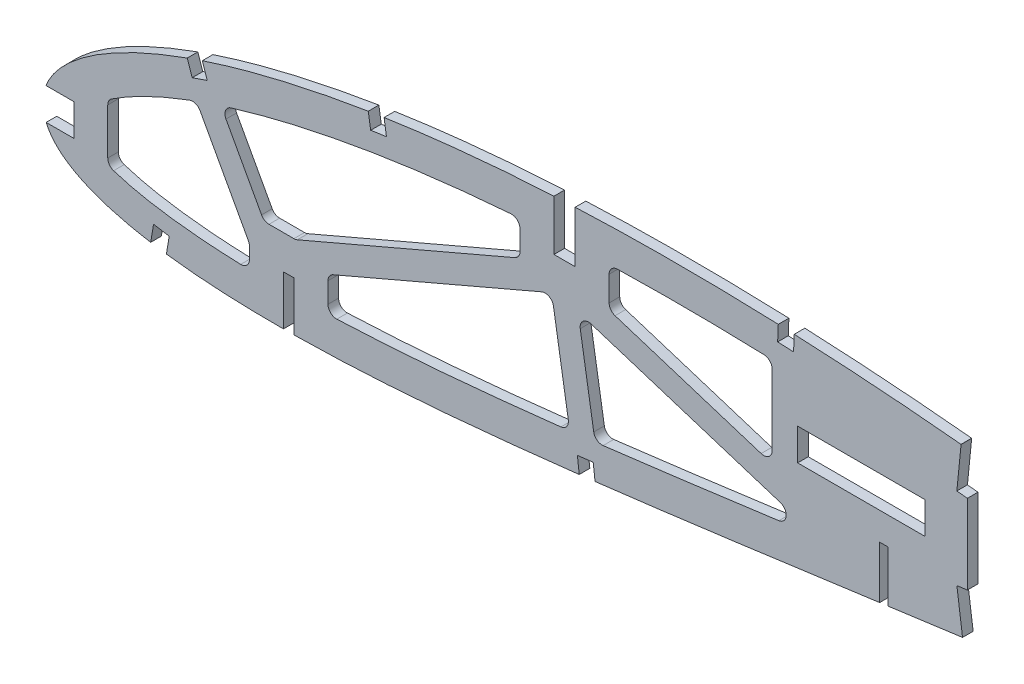
from build123d import *

# Parameters (mm, degrees)
BOSS_EXTRUDE1_DEPTH = 3.175
CUT_EXTRUDE1_DEPTH  = 7.62
SKETCH3_R           = 6.35
CUT_EXTRUDE2_DEPTH  = 7.62
SKETCH4_W           = 38.1
SKETCH4_H           = 9.525
SKETCH4_R           = 6.35
CUT_EXTRUDE3_DEPTH  = 4.1750001
CUT_EXTRUDE4_DEPTH  = 4.1750001
FILLET1_R           = 2.54


with BuildPart() as part:
    # Sketch1 → Boss-Extrude1 (new body)
    with BuildSketch(Plane.XY):
        with BuildLine():
            Line((435.33010469, 0.678691456), (439.172882547, -1.614212492))
            Line((439.172882547, -1.614212492), (434.787151486, -0.678691456))
            add(Edge.make_bspline(
                [(0, 0), (0.11179123, -0.527729161), (0.335887463, -1.58561283), (0.94472768, -3.108527015), (1.749889805, -4.572488672), (2.768272335, -5.973609192), (3.993104005, -7.311505618), (5.421679636, -8.587569541), (7.052598221, -9.801114861), (8.883725224, -10.951589231), (10.912400596, -12.040213999), (13.136344152, -13.066312264), (15.553528081, -14.029563428), (18.161318821, -14.928679795), (20.956528242, -15.765030781), (23.936498821, -16.536578215), (27.097842034, -17.244400464), (30.437517266, -17.886690773), (33.951885298, -18.464101669), (37.637295209, -18.976309975), (41.489964184, -19.423636044), (45.506112459, -19.80514129), (49.681767661, -20.121646285), (54.012767863, -20.373360955), (58.494909036, -20.561083494), (63.123897762, -20.684100336), (67.895200479, -20.744329207), (72.804505265, -20.742674403), (77.847009648, -20.678693244), (83.018406129, -20.555920262), (88.313732191, -20.373577887), (93.728207214, -20.133872554), (99.256947275, -19.839216685), (104.89499369, -19.49060908), (110.637384794, -19.089594814), (116.479134607, -18.639389777), (122.414936441, -18.141116951), (128.439613477, -17.597680601), (134.547832047, -17.011801372), (140.734314746, -16.385333349), (146.993600903, -15.721223571), (153.320115485, -15.021624036), (159.708476563, -14.290267097), (166.152848405, -13.528475979), (172.647781594, -12.740600204), (179.187166024, -11.928145018), (185.765533466, -11.094239816), (192.376967293, -10.242811017), (199.015278084, -9.37376151), (205.674882543, -8.493282903), (212.349358377, -7.600650086), (219.032895906, -6.7004538), (225.719308248, -5.795492203), (232.402082768, -4.886043807), (239.075345122, -3.975877517), (245.732904616, -3.06749205), (252.368240069, -2.160970285), (258.975348295, -1.26081803), (265.547576185, -0.366925322), (272.078863439, 0.518895586), (278.562951189, 1.394000598), (284.993721977, 2.257285217), (291.364542133, 3.108203268), (297.66900214, 3.947074317), (303.806375969, 4.748436439), (309.760626579, 5.554962658), (315.551818652, 6.216135275), (321.27090305, 6.780469964), (326.923820465, 7.243146515), (332.503782957, 7.610821489), (338.004397185, 7.886122043), (343.419107553, 8.072891719), (348.74107448, 8.176671364), (353.963650696, 8.200094537), (359.079707468, 8.150631139), (364.082590991, 8.032268225), (368.965318868, 7.850318702), (373.721079318, 7.610921079), (378.343117125, 7.320601554), (382.824493294, 6.983642622), (387.158963185, 6.607910686), (391.339839301, 6.198906082), (395.360701925, 5.761301701), (399.215684034, 5.304267166), (402.898615263, 4.830811549), (406.403955911, 4.348715399), (409.726063296, 3.862864382), (412.859676284, 3.379461168), (415.799871302, 2.903117573), (418.541899149, 2.440155772), (421.081464376, 1.994901374), (423.414160264, 1.571702591), (425.536750687, 1.175899009), (427.445043551, 0.809456817), (429.136486586, 0.478415007), (430.607934716, 0.184234372), (431.857230885, -0.068940506), (432.88219343, -0.280110359), (433.681265576, -0.445808771), (434.252869013, -0.566300363), (434.596385478, -0.637999126), (434.749014267, -0.670556399), (434.787151486, -0.678691456)],
                knots=[0, 0, 0, 0, 0.003638255, 0.007293231, 0.011028136, 0.014901081, 0.018963272, 0.023258475, 0.027820626, 0.032679082, 0.03785316, 0.043361875, 0.049214679, 0.055422346, 0.061988786, 0.068918036, 0.076211157, 0.083868392, 0.091887411, 0.100265912, 0.108999867, 0.118084529, 0.127514843, 0.13728527, 0.147387917, 0.157816481, 0.168563473, 0.179619128, 0.190977373, 0.202626974, 0.214560478, 0.226767249, 0.239236417, 0.251959004, 0.264923894, 0.278119703, 0.291536035, 0.30516028, 0.318980685, 0.332985499, 0.34716279, 0.361498603, 0.375980747, 0.390597192, 0.405332593, 0.420174823, 0.435109533, 0.450124276, 0.465203068, 0.480333154, 0.495500583, 0.510689775, 0.525887334, 0.541078314, 0.556247233, 0.571381785, 0.58646604, 0.601484515, 0.616424329, 0.631269423, 0.646006524, 0.660620684, 0.675098187, 0.689422858, 0.703581825, 0.716907563, 0.730009274, 0.742952128, 0.755725557, 0.768319951, 0.780724337, 0.792926528, 0.804916041, 0.816679084, 0.828203525, 0.8394749, 0.850481359, 0.861207697, 0.871639326, 0.881763414, 0.891563605, 0.901027365, 0.910138977, 0.918883977, 0.927249278, 0.935221104, 0.942784739, 0.949928188, 0.956638465, 0.962904203, 0.968712288, 0.974054485, 0.978918432, 0.983297219, 0.987180246, 0.990560674, 0.993433357, 0.995790626, 0.997629588, 0.998945816, 0.999736592, 1, 1, 1, 1], degree=3))
            add(Edge.make_bspline(
                [(435.33010469, 0.678691456), (435.296755582, 0.699293055), (435.163488681, 0.781619431), (434.863214309, 0.965803828), (434.363194901, 1.272571896), (433.663211466, 1.69979322), (432.763807452, 2.246333125), (431.664530435, 2.908364558), (430.366066728, 3.683736897), (428.86873043, 4.568782589), (427.172675107, 5.559358025), (425.278546429, 6.651449737), (423.186509465, 7.838875427), (420.897374442, 9.116782681), (418.411926851, 10.4790944), (415.730636684, 11.919657082), (412.854464224, 13.43114364), (409.784513475, 15.00705265), (406.521344218, 16.638681918), (403.066494801, 18.319240705), (399.421116368, 20.040349747), (395.586453278, 21.79282696), (391.56470833, 23.569527811), (387.356993489, 25.359407096), (382.965706604, 27.15470981), (378.392717175, 28.945218407), (373.640732922, 30.722778715), (368.711587102, 32.475875028), (363.608964359, 34.196846251), (358.335340013, 35.87451254), (352.894485425, 37.499762392), (347.289561815, 39.062058655), (341.52524157, 40.553388886), (335.605180365, 41.962892679), (329.534395845, 43.28113527), (323.317713598, 44.500180123), (316.960347344, 45.607856696), (310.479914041, 46.603301327), (303.980682286, 47.431342852), (297.494822244, 48.243461645), (291.0186212, 49.006373108), (284.46326746, 49.736966294), (277.835067652, 50.431127833), (271.140596349, 51.086687253), (264.386630807, 51.700815013), (257.580189535, 52.27171033), (250.727858804, 52.796138155), (243.836864005, 53.273290553), (236.914017847, 53.698972807), (229.966694004, 54.072865307), (223.001944897, 54.392360355), (216.027018499, 54.655256617), (209.049321182, 54.859966995), (202.076096041, 55.004530305), (195.114893299, 55.088037667), (188.172953688, 55.108207309), (181.257823923, 55.064678381), (174.376745271, 54.95595632), (167.537272154, 54.780552763), (160.7466557, 54.538140281), (154.012238926, 54.228824112), (147.341395315, 53.850013849), (140.741361553, 53.404123644), (134.219487317, 52.889280335), (127.782938298, 52.305347044), (121.438460058, 51.65475786), (115.193116172, 50.935743156), (109.053599754, 50.150348891), (103.026626206, 49.300114834), (97.118957953, 48.384577869), (91.33692342, 47.406382542), (85.686763085, 46.366529581), (80.174454785, 45.268067638), (74.805999973, 44.111283189), (69.587081438, 42.899646299), (64.52312301, 41.635267927), (59.619568317, 40.320462769), (54.881388132, 38.958385816), (50.313373811, 37.552127128), (45.920850559, 36.103231966), (41.707138151, 34.617193881), (37.677412709, 33.095067788), (33.834761135, 31.541542875), (30.183686712, 29.958740393), (26.726916941, 28.351485511), (23.468364091, 26.721608068), (20.41035055, 25.073674406), (17.555946308, 23.410211446), (14.907899047, 21.73430892), (12.467321746, 20.050217809), (10.237579271, 18.35899521), (8.219437586, 16.664914738), (6.414173801, 14.97055608), (4.824368385, 13.277086383), (3.449964137, 11.587487839), (2.292762263, 9.903098559), (1.352963468, 8.225512409), (0.632693499, 6.555947979), (0.13123808, 4.895344207), (-0.143255259, 3.246152095), (-0.211578297, 1.607049514), (-0.07042072, 0.534882766), (0, 0)],
                knots=[0, 0, 0, 0, 0.00025409, 0.001015373, 0.002283359, 0.004056577, 0.006330982, 0.009105274, 0.012374489, 0.016134023, 0.02037966, 0.025105976, 0.030306237, 0.035972206, 0.042099522, 0.048678064, 0.055701664, 0.063160184, 0.071045824, 0.079349826, 0.08806291, 0.097175756, 0.106678112, 0.116561573, 0.126814275, 0.137428301, 0.148393618, 0.15969976, 0.171338126, 0.183297699, 0.195569604, 0.208143556, 0.221011593, 0.234161831, 0.24758745, 0.261276822, 0.27522271, 0.289414144, 0.303771199, 0.317689227, 0.331784111, 0.346039677, 0.36044387, 0.37498272, 0.389640454, 0.404403316, 0.419256601, 0.434186749, 0.449177265, 0.464214782, 0.479284009, 0.49436974, 0.509457833, 0.524532346, 0.53957932, 0.554582984, 0.569529546, 0.584403417, 0.599190992, 0.613876838, 0.628447475, 0.642888675, 0.657186054, 0.671325546, 0.685294014, 0.699078147, 0.712665095, 0.726042645, 0.739197713, 0.752117586, 0.764792042, 0.777208152, 0.789355685, 0.80122396, 0.812803686, 0.824082909, 0.835054602, 0.845709571, 0.856037853, 0.866033834, 0.875688843, 0.884997719, 0.893953426, 0.902552897, 0.910789386, 0.918660734, 0.926166253, 0.933302626, 0.94007122, 0.94647478, 0.952517526, 0.958204819, 0.963546652, 0.9685566, 0.973249913, 0.977651041, 0.981787043, 0.985694226, 0.989415109, 0.993001157, 0.996508416, 1, 1, 1, 1], degree=3))
        make_face()
    extrude(amount=BOSS_EXTRUDE1_DEPTH)

    # Sketch2 → Cut-Extrude1 (cut)
    with BuildSketch(Plane(origin=(0, 0, 0), x_dir=(-1, 0, 0), z_dir=(0, 0, -1))):
        Polygon((-252.794440989, 13.221493744), (-250.254440989, 13.221493744), (-250.254440989, -2.115243028), (-250.254440989, -3.986349358), (-252.794440989, -3.050796193), (-252.794440989, -2.115243028), align=None)
        Polygon((-159.131940989, 54.422217902), (-159.131940989, 39.039100326), (-152.781940989, 39.039100326), (-152.781940989, 54.422217902), (-152.781940989, 57.645440557), (-159.131940989, 55.540936844), align=None)
        Polygon((-74.994440989, -5.928775484), (-74.994440989, -20.141805429), (-74.994440989, -20.97642061), (-71.819440989, -22.145862066), (-71.819440989, -20.141805429), (-71.819440989, -5.928775484), align=None)
    extrude(amount=-CUT_EXTRUDE1_DEPTH, mode=Mode.SUBTRACT)

    # Sketch3 → Cut-Extrude2 (cut)
    with BuildSketch(Plane(origin=(0, 0, 0), x_dir=(-1, 0, 0), z_dir=(0, 0, -1))):
        with Locations((-292.383806588, 26.255421435)):
            Circle(SKETCH3_R)
    extrude(amount=-CUT_EXTRUDE2_DEPTH, mode=Mode.SUBTRACT)

    # Sketch4 → Cut-Extrude3 (cut, through all)
    with BuildSketch(Plane.XY.offset(3.175)):
        with BuildLine():
            Line((9.08354865, 6.810338827), (0.76430461, 6.810338827))
            add(Edge.make_bspline(
                [(0.76430461, 6.810338827), (0.726676763, 6.71299191), (0.488212559, 6.077489506), (0.13123808, 4.895344207), (-0.143255259, 3.246152095), (-0.211578297, 1.607049514), (-0.07042072, 0.534882766), (0, 0)],
                knots=[0.98501809, 0.98501809, 0.98501809, 0.98501809, 0.985694226, 0.989415109, 0.993001157, 0.996508416, 1, 1, 1, 1], degree=3))
            add(Edge.make_bspline(
                [(0, 0), (0.11179123, -0.527729161), (0.307969583, -1.453821818), (0.640979835, -2.341032636), (0.803006074, -2.714661173)],
                knots=[0, 0, 0, 0, 0.003638255, 0.006384641, 0.006384641, 0.006384641, 0.006384641], degree=3))
            Line((0.803006074, -2.714661173), (9.08354865, -2.714661173))
            Line((9.08354865, -2.714661173), (9.08354865, 6.810338827))
        make_face()
        with BuildLine():
            Line((49.020517996, 32.253888691), (47.531675541, 36.629642878))
            add(Edge.make_bspline(
                [(47.531675541, 36.629642878), (46.979087567, 36.445759538), (45.474608141, 35.938686183), (43.975608762, 35.415532918), (43.028960398, 35.077347923)],
                knots=[0.862258912, 0.862258912, 0.862258912, 0.862258912, 0.866033834, 0.872549698, 0.872549698, 0.872549698, 0.872549698], degree=3))
            Line((43.028960398, 35.077347923), (44.512019179, 30.71972624))
            Line((44.512019179, 30.71972624), (49.020517996, 32.253888691))
        make_face()
        Polygon((36.838817299, -18.581245887), (32.165910286, -17.731153874), (32.952371753, -13.02357497), (37.641753761, -13.808241987), align=None)
        with BuildLine():
            Line((102.645386654, 44.510393866), (101.9478561, 49.125267329))
            add(Edge.make_bspline(
                [(101.9478561, 49.125267329), (100.365650198, 48.887111331), (98.784740474, 48.64033843), (97.205261705, 48.38471328)],
                knots=[0.741480352, 0.741480352, 0.741480352, 0.741480352, 0.751851659, 0.751851659, 0.751851659, 0.751851659], degree=3))
            Line((97.205261705, 48.38471328), (97.936400792, 43.798607145))
            Line((97.936400792, 43.798607145), (102.645386654, 44.510393866))
        make_face()
        with BuildLine():
            add(Edge.make_bspline(
                [(160.340338786, -14.212647666), (161.920044437, -14.028275741), (163.499504121, -13.841797301), (165.078745983, -13.653492366)],
                knots=[0.377458898, 0.377458898, 0.377458898, 0.377458898, 0.388202054, 0.388202054, 0.388202054, 0.388202054], degree=3))
            Line((165.078745983, -13.653492366), (164.522590598, -8.953423812))
            Line((164.522590598, -8.953423812), (159.793087001, -9.513059826))
            Line((159.793087001, -9.513059826), (160.340338786, -14.212647666))
        make_face()
        with BuildLine():
            Line((224.483551568, 49.643099482), (224.695252101, 54.310425843))
            add(Edge.make_bspline(
                [(224.695252101, 54.310425843), (224.131555977, 54.335094277), (222.536497131, 54.403324951), (220.941251233, 54.467084737), (219.909719875, 54.506423891)],
                knots=[0.475626644, 0.475626644, 0.475626644, 0.475626644, 0.479284009, 0.485975235, 0.485975235, 0.485975235, 0.485975235], degree=3))
            Line((219.909719875, 54.506423891), (219.725798523, 49.849814949))
            Line((219.725798523, 49.849814949), (224.483551568, 49.643099482))
        make_face()
        with Locations((244.758806588, 26.255421435)):
            Rectangle(SKETCH4_W, SKETCH4_H)
        Polygon((276.508806588, 37.713859181), (277.787367709, 50.342830172), (274.606587067, 50.664683683), (273.349658498, 38.028091323), align=None)
        with BuildLine():
            Line((274.606587067, 50.745349283), (274.606587067, 50.664683683))
            Line((274.606587067, 50.664683683), (277.787367709, 50.342830172))
            Line((277.787367709, 50.342830172), (276.508806588, 37.713859181))
            Line((276.508806588, 37.713859181), (276.508806588, 13.934637567))
            Line((276.508806588, 13.934637567), (278.202158297, 1.347675194))
            Line((278.202158297, 1.347675194), (275.057635426, 0.924468904))
            Line((275.057635426, 0.924468904), (275.057635426, 0.920727129))
            add(Edge.make_bspline(
                [(275.057635426, 0.920727129), (276.232091103, 1.079260303), (279.550679689, 1.526596029), (284.993721977, 2.257285217), (291.364542133, 3.108203268), (297.66900214, 3.947074317), (303.806375969, 4.748436439), (309.760626579, 5.554962658), (315.551818652, 6.216135275), (321.27090305, 6.780469964), (326.923820465, 7.243146515), (332.503782957, 7.610821489), (338.004397185, 7.886122043), (343.419107553, 8.072891719), (348.74107448, 8.176671364), (353.963650696, 8.200094537), (359.079707468, 8.150631139), (364.082590991, 8.032268225), (368.965318868, 7.850318702), (373.721079318, 7.610921079), (378.343117125, 7.320601554), (382.824493294, 6.983642622), (387.158963185, 6.607910686), (391.339839301, 6.198906082), (395.360701925, 5.761301701), (399.215684034, 5.304267166), (402.898615263, 4.830811549), (406.403955911, 4.348715399), (409.726063296, 3.862864382), (412.859676284, 3.379461168), (415.799871302, 2.903117573), (418.541899149, 2.440155772), (421.081464376, 1.994901374), (423.414160264, 1.571702591), (425.536750687, 1.175899009), (427.445043551, 0.809456817), (429.136486586, 0.478415007), (430.607934716, 0.184234372), (431.857230885, -0.068940506), (432.88219343, -0.280110359), (433.681265576, -0.445808771), (434.252869013, -0.566300363), (434.596385478, -0.637999126), (434.749014267, -0.670556399), (434.787151486, -0.678691456)],
                knots=[0.638001263, 0.638001263, 0.638001263, 0.638001263, 0.646006524, 0.660620684, 0.675098187, 0.689422858, 0.703581825, 0.716907563, 0.730009274, 0.742952128, 0.755725557, 0.768319951, 0.780724337, 0.792926528, 0.804916041, 0.816679084, 0.828203525, 0.8394749, 0.850481359, 0.861207697, 0.871639326, 0.881763414, 0.891563605, 0.901027365, 0.910138977, 0.918883977, 0.927249278, 0.935221104, 0.942784739, 0.949928188, 0.956638465, 0.962904203, 0.968712288, 0.974054485, 0.978918432, 0.983297219, 0.987180246, 0.990560674, 0.993433357, 0.995790626, 0.997629588, 0.998945816, 0.999736592, 1, 1, 1, 1], degree=3))
            Line((434.787151486, -0.678691456), (439.172882547, -1.614212492))
            Line((439.172882547, -1.614212492), (435.33010469, 0.678691456))
            add(Edge.make_bspline(
                [(435.33010469, 0.678691456), (435.296755582, 0.699293055), (435.163488681, 0.781619431), (434.863214309, 0.965803828), (434.363194901, 1.272571896), (433.663211466, 1.69979322), (432.763807452, 2.246333125), (431.664530435, 2.908364558), (430.366066728, 3.683736897), (428.86873043, 4.568782589), (427.172675107, 5.559358025), (425.278546429, 6.651449737), (423.186509465, 7.838875427), (420.897374442, 9.116782681), (418.411926851, 10.4790944), (415.730636684, 11.919657082), (412.854464224, 13.43114364), (409.784513475, 15.00705265), (406.521344218, 16.638681918), (403.066494801, 18.319240705), (399.421116368, 20.040349747), (395.586453278, 21.79282696), (391.56470833, 23.569527811), (387.356993489, 25.359407096), (382.965706604, 27.15470981), (378.392717175, 28.945218407), (373.640732922, 30.722778715), (368.711587102, 32.475875028), (363.608964359, 34.196846251), (358.335340013, 35.87451254), (352.894485425, 37.499762392), (347.289561815, 39.062058655), (341.52524157, 40.553388886), (335.605180365, 41.962892679), (329.534395845, 43.28113527), (323.317713598, 44.500180123), (316.960347344, 45.607856696), (310.479914041, 46.603301327), (303.980682286, 47.431342852), (297.494822244, 48.243461645), (291.0186212, 49.006373108), (284.46326746, 49.736966294), (278.983592298, 50.31084455), (275.689561404, 50.639206846), (274.606587067, 50.745349283)],
                knots=[0, 0, 0, 0, 0.00025409, 0.001015373, 0.002283359, 0.004056577, 0.006330982, 0.009105274, 0.012374489, 0.016134023, 0.02037966, 0.025105976, 0.030306237, 0.035972206, 0.042099522, 0.048678064, 0.055701664, 0.063160184, 0.071045824, 0.079349826, 0.08806291, 0.097175756, 0.106678112, 0.116561573, 0.126814275, 0.137428301, 0.148393618, 0.15969976, 0.171338126, 0.183297699, 0.195569604, 0.208143556, 0.221011593, 0.234161831, 0.24758745, 0.261276822, 0.27522271, 0.289414144, 0.303771199, 0.317689227, 0.331784111, 0.346039677, 0.36044387, 0.367497329, 0.367497329, 0.367497329, 0.367497329], degree=3))
        make_face()
        with Locations((292.383806588, 26.255421435)):
            Circle(SKETCH4_R, mode=Mode.SUBTRACT)
        Polygon((273.362227422, 13.510785566), (275.057635426, 0.924468904), (278.202158297, 1.347675194), (276.508806588, 13.934637567), align=None)
        with BuildLine():
            add(Edge.make_bspline(
                [(32.095086313, -18.155090016), (32.696595442, -18.254411923), (34.259232792, -18.501714728), (35.825676123, -18.723786999), (36.789618427, -18.851689263)],
                knots=[0.087769382, 0.087769382, 0.087769382, 0.087769382, 0.091887411, 0.098455639, 0.098455639, 0.098455639, 0.098455639], degree=3))
            Line((32.095086313, -18.155090016), (31.569110721, -21.303459904))
            Line((31.569110721, -21.303459904), (36.2027681, -22.077571832))
            Line((36.2027681, -22.077571832), (36.789618427, -18.851689263))
        make_face()
        with BuildLine():
            Line((32.165910286, -17.731153874), (32.095086313, -18.155090016))
            add(Edge.make_bspline(
                [(32.095086313, -18.155090016), (32.696595442, -18.254411923), (34.259232792, -18.501714728), (35.825676123, -18.723786999), (36.789618427, -18.851689263)],
                knots=[0.087769382, 0.087769382, 0.087769382, 0.087769382, 0.091887411, 0.098455639, 0.098455639, 0.098455639, 0.098455639], degree=3))
            Line((36.789618427, -18.851689263), (36.838817299, -18.581245887))
            Line((36.838817299, -18.581245887), (32.165910286, -17.731153874))
        make_face()
    extrude(amount=-CUT_EXTRUDE3_DEPTH, mode=Mode.SUBTRACT)

    # Sketch5 → Cut-Extrude4 (cut, through all)
    with BuildSketch(Plane.XY.offset(3.175)):
        with BuildLine():
            add(Edge.make_bspline(
                [(45.814840569, 25.282367443), (43.822791815, 24.562865162), (39.215196122, 22.812244039), (32.181765676, 19.775215547), (26.104065444, 16.671015264), (22.150956813, 14.309546417), (20.27302683, 13.083140574), (19.503800794, 12.556245905), (19.24354865, 12.374877898)],
                knots=[0.874077053, 0.874077053, 0.874077053, 0.874077053, 0.888527775, 0.907825838, 0.927123901, 0.936772932, 0.94141287, 0.943825127, 0.943825127, 0.943825127, 0.943825127], degree=3))
            Line((19.24354865, 12.374877898), (19.24354865, -4.539137798))
            add(Edge.make_bspline(
                [(19.24354865, -4.539137798), (19.525981613, -4.642890342), (20.216795523, -4.889295377), (22.0966215, -5.515008888), (26.203155938, -6.690360656), (32.713182772, -8.045600453), (40.841334575, -9.183638157), (49.096619858, -9.934839763), (55.360075179, -10.273048988), (59.539003509, -10.420924337), (60.952190291, -10.460753472), (61.659440989, -10.478274979)],
                knots=[0.049763351, 0.049763351, 0.049763351, 0.049763351, 0.052230608, 0.055729778, 0.065598805, 0.08533686, 0.105074914, 0.124812969, 0.144188224, 0.149122738, 0.154057251, 0.154057251, 0.154057251, 0.154057251], degree=3))
            Line((61.659440989, -10.478274979), (61.659440989, -3.714397612))
            Line((61.659440989, -3.714397612), (45.814840569, 25.282367443))
        make_face()
        with BuildLine():
            add(Edge.make_bspline(
                [(142.621940989, 43.341052807), (141.16277336, 43.237100158), (137.894505535, 42.99177607), (128.804678048, 42.228619487), (115.386854733, 40.817080153), (98.089203191, 38.358558503), (80.973623404, 35.187832938), (66.936657893, 31.856735994), (57.726991023, 29.21501171), (54.069296834, 28.07024065), (53.137796451, 27.772072652)],
                knots=[0.654625525, 0.654625525, 0.654625525, 0.654625525, 0.664274557, 0.676249084, 0.714845209, 0.753441335, 0.792037461, 0.830633587, 0.84993165, 0.856554759, 0.856554759, 0.856554759, 0.856554759], degree=3))
            Line((53.137796451, 27.772072652), (66.001139364, 4.231224516))
            Line((66.001139364, 4.231224516), (75.488690109, 4.231224516))
            Line((75.488690109, 4.231224516), (142.621940989, 33.024751821))
            Line((142.621940989, 33.024751821), (142.621940989, 43.341052807))
        make_face()
        with BuildLine():
            Line((85.154440989, 0.085573021), (85.154440989, -10.31403894))
            add(Edge.make_bspline(
                [(85.154440989, -10.31403894), (90.221688375, -10.141635354), (101.039010532, -9.613219564), (117.637914667, -8.40013339), (136.679570306, -6.638548813), (149.971615588, -5.18667662), (157.497572739, -4.315203925)],
                knots=[0.208311845, 0.208311845, 0.208311845, 0.208311845, 0.243241296, 0.282717405, 0.322193514, 0.373662797, 0.373662797, 0.373662797, 0.373662797], degree=3))
            Line((157.497572739, -4.315203925), (152.109291457, 28.802584187))
            Line((152.109291457, 28.802584187), (85.154440989, 0.085573021))
        make_face()
        with BuildLine():
            Line((159.987096536, 27.833886694), (165.07247877, -3.422204529))
            add(Edge.make_bspline(
                [(165.07247877, -3.422204529), (166.566956941, -3.243055154), (179.610552739, -1.664978362), (201.671667741, 1.19592823), (222.259411164, 3.987166397), (231.282036291, 5.215897599)],
                knots=[0.390928193, 0.390928193, 0.390928193, 0.390928193, 0.401145733, 0.480097951, 0.541640306, 0.541640306, 0.541640306, 0.541640306], degree=3))
            Line((231.282036291, 5.215897599), (159.987096536, 27.833886694))
        make_face()
        with BuildLine():
            add(Edge.make_bspline(
                [(218.088806588, 44.407248442), (215.149456111, 44.514285011), (209.270778872, 44.697237468), (195.225915283, 44.981634592), (181.89596248, 44.964543834), (171.518848439, 44.720101194), (169.291940989, 44.656607646)],
                knots=[0.489112922, 0.489112922, 0.489112922, 0.489112922, 0.508410985, 0.527709048, 0.581332198, 0.595990863, 0.595990863, 0.595990863, 0.595990863], degree=3))
            Line((169.291940989, 44.656607646), (169.291940989, 32.87623272))
            Line((169.291940989, 32.87623272), (218.088806588, 17.395653345))
            Line((218.088806588, 17.395653345), (218.088806588, 38.637921435))
            Line((218.088806588, 38.637921435), (218.088806588, 44.407248442))
        make_face()
    extrude(amount=-CUT_EXTRUDE4_DEPTH, mode=Mode.SUBTRACT)

    # Fillet1
    fillet1_edges = [part.edges().sort_by_distance(p)[0] for p in [
        (169.291940989, 32.87623272, 1.5875),
        (169.291940989, 44.656607646, 1.5875),
        (218.088806588, 44.407248442, 1.5875),
        (218.088806588, 17.395653345, 1.5875),
        (19.24354865, 12.374877898, 1.5875),
        (45.814840569, 25.282367443, 1.5875),
        (61.659440989, -3.714397612, 1.5875),
        (19.24354865, -4.539137798, 1.5875),
        (85.154440989, 0.085573021, 1.5875),
        (152.109291457, 28.802584187, 1.5875),
        (157.497572739, -4.315203925, 1.5875),
        (85.154440989, -10.31403894, 1.5875),
        (142.621940989, 33.024751821, 1.5875),
        (75.488690109, 4.231224516, 1.5875),
        (66.001139364, 4.231224516, 1.5875),
        (53.137796451, 27.772072652, 1.5875),
        (142.621940989, 43.341052807, 1.5875),
        (159.987096536, 27.833886694, 1.5875),
        (231.282036291, 5.215897599, 1.5875),
        (165.07247877, -3.422204529, 1.5875),
        (61.659440989, -10.478274979, 1.5875),
    ]]
    fillet(fillet1_edges, radius=FILLET1_R)


solid = part.part
